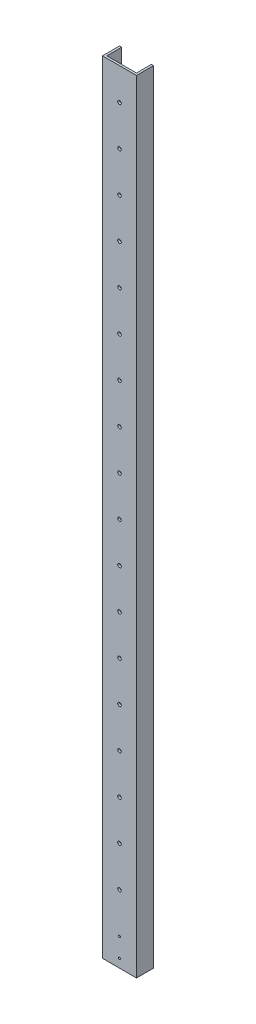
from build123d import *

# Parameters (mm, degrees)
BOSS_EXTRUDE1_DEPTH = 1168.4
CUT_EXTRUDE1_REACH  = 27.4
SKETCH2_R           = 2.667
CUT_EXTRUDE2_REACH  = 27.4
SKETCH4_R           = 1.5875


with BuildPart() as part:
    # Sketch1 → Boss-Extrude1 (new body)
    with BuildSketch(Plane(origin=(0, 0, 0), x_dir=(1, 0, 0), z_dir=(0, 1, 0))):
        Polygon((3.175, 3.175), (3.175, 25.4), (0, 25.4), (0, 0), (50.8, 0), (50.8, 25.4), (47.625, 25.4), (47.625, 3.175), align=None)
    extrude(amount=BOSS_EXTRUDE1_DEPTH)

    # Sketch2 → Cut-Extrude1 (cut, up to next)
    with BuildSketch(Plane.XY, mode=Mode.PRIVATE) as cut_extrude1_sk1:
        with Locations((25.4, 101.6)):
            Circle(SKETCH2_R)
    cut_extrude1_tool1 = extrude(cut_extrude1_sk1.sketch, amount=-CUT_EXTRUDE1_REACH, mode=Mode.PRIVATE) & part.part
    add(cut_extrude1_tool1.solids().sort_by_distance((25.4, 101.6, 0))[0], mode=Mode.SUBTRACT)
    # Sketch2 → Cut-Extrude1 (cut, up to next)
    with BuildSketch(Plane.XY, mode=Mode.PRIVATE) as cut_extrude1_sk2:
        with Locations((25.4, 161.544)):
            Circle(SKETCH2_R)
    cut_extrude1_tool2 = extrude(cut_extrude1_sk2.sketch, amount=-CUT_EXTRUDE1_REACH, mode=Mode.PRIVATE) & part.part
    add(cut_extrude1_tool2.solids().sort_by_distance((25.4, 161.544, 0))[0], mode=Mode.SUBTRACT)
    # Sketch2 → Cut-Extrude1 (cut, up to next)
    with BuildSketch(Plane.XY, mode=Mode.PRIVATE) as cut_extrude1_sk3:
        with Locations((25.4, 221.488)):
            Circle(SKETCH2_R)
    cut_extrude1_tool3 = extrude(cut_extrude1_sk3.sketch, amount=-CUT_EXTRUDE1_REACH, mode=Mode.PRIVATE) & part.part
    add(cut_extrude1_tool3.solids().sort_by_distance((25.4, 221.488, 0))[0], mode=Mode.SUBTRACT)
    # Sketch2 → Cut-Extrude1 (cut, up to next)
    with BuildSketch(Plane.XY, mode=Mode.PRIVATE) as cut_extrude1_sk4:
        with Locations((25.4, 281.432)):
            Circle(SKETCH2_R)
    cut_extrude1_tool4 = extrude(cut_extrude1_sk4.sketch, amount=-CUT_EXTRUDE1_REACH, mode=Mode.PRIVATE) & part.part
    add(cut_extrude1_tool4.solids().sort_by_distance((25.4, 281.432, 0))[0], mode=Mode.SUBTRACT)
    # Sketch2 → Cut-Extrude1 (cut, up to next)
    with BuildSketch(Plane.XY, mode=Mode.PRIVATE) as cut_extrude1_sk5:
        with Locations((25.4, 341.376)):
            Circle(SKETCH2_R)
    cut_extrude1_tool5 = extrude(cut_extrude1_sk5.sketch, amount=-CUT_EXTRUDE1_REACH, mode=Mode.PRIVATE) & part.part
    add(cut_extrude1_tool5.solids().sort_by_distance((25.4, 341.376, 0))[0], mode=Mode.SUBTRACT)
    # Sketch2 → Cut-Extrude1 (cut, up to next)
    with BuildSketch(Plane.XY, mode=Mode.PRIVATE) as cut_extrude1_sk6:
        with Locations((25.4, 401.32)):
            Circle(SKETCH2_R)
    cut_extrude1_tool6 = extrude(cut_extrude1_sk6.sketch, amount=-CUT_EXTRUDE1_REACH, mode=Mode.PRIVATE) & part.part
    add(cut_extrude1_tool6.solids().sort_by_distance((25.4, 401.32, 0))[0], mode=Mode.SUBTRACT)
    # Sketch2 → Cut-Extrude1 (cut, up to next)
    with BuildSketch(Plane.XY, mode=Mode.PRIVATE) as cut_extrude1_sk7:
        with Locations((25.4, 461.264)):
            Circle(SKETCH2_R)
    cut_extrude1_tool7 = extrude(cut_extrude1_sk7.sketch, amount=-CUT_EXTRUDE1_REACH, mode=Mode.PRIVATE) & part.part
    add(cut_extrude1_tool7.solids().sort_by_distance((25.4, 461.264, 0))[0], mode=Mode.SUBTRACT)
    # Sketch2 → Cut-Extrude1 (cut, up to next)
    with BuildSketch(Plane.XY, mode=Mode.PRIVATE) as cut_extrude1_sk8:
        with Locations((25.4, 521.208)):
            Circle(SKETCH2_R)
    cut_extrude1_tool8 = extrude(cut_extrude1_sk8.sketch, amount=-CUT_EXTRUDE1_REACH, mode=Mode.PRIVATE) & part.part
    add(cut_extrude1_tool8.solids().sort_by_distance((25.4, 521.208, 0))[0], mode=Mode.SUBTRACT)
    # Sketch2 → Cut-Extrude1 (cut, up to next)
    with BuildSketch(Plane.XY, mode=Mode.PRIVATE) as cut_extrude1_sk9:
        with Locations((25.4, 581.152)):
            Circle(SKETCH2_R)
    cut_extrude1_tool9 = extrude(cut_extrude1_sk9.sketch, amount=-CUT_EXTRUDE1_REACH, mode=Mode.PRIVATE) & part.part
    add(cut_extrude1_tool9.solids().sort_by_distance((25.4, 581.152, 0))[0], mode=Mode.SUBTRACT)
    # Sketch2 → Cut-Extrude1 (cut, up to next)
    with BuildSketch(Plane.XY, mode=Mode.PRIVATE) as cut_extrude1_sk10:
        with Locations((25.4, 641.096)):
            Circle(SKETCH2_R)
    cut_extrude1_tool10 = extrude(cut_extrude1_sk10.sketch, amount=-CUT_EXTRUDE1_REACH, mode=Mode.PRIVATE) & part.part
    add(cut_extrude1_tool10.solids().sort_by_distance((25.4, 641.096, 0))[0], mode=Mode.SUBTRACT)
    # Sketch2 → Cut-Extrude1 (cut, up to next)
    with BuildSketch(Plane.XY, mode=Mode.PRIVATE) as cut_extrude1_sk11:
        with Locations((25.4, 701.04)):
            Circle(SKETCH2_R)
    cut_extrude1_tool11 = extrude(cut_extrude1_sk11.sketch, amount=-CUT_EXTRUDE1_REACH, mode=Mode.PRIVATE) & part.part
    add(cut_extrude1_tool11.solids().sort_by_distance((25.4, 701.04, 0))[0], mode=Mode.SUBTRACT)
    # Sketch2 → Cut-Extrude1 (cut, up to next)
    with BuildSketch(Plane.XY, mode=Mode.PRIVATE) as cut_extrude1_sk12:
        with Locations((25.4, 760.984)):
            Circle(SKETCH2_R)
    cut_extrude1_tool12 = extrude(cut_extrude1_sk12.sketch, amount=-CUT_EXTRUDE1_REACH, mode=Mode.PRIVATE) & part.part
    add(cut_extrude1_tool12.solids().sort_by_distance((25.4, 760.984, 0))[0], mode=Mode.SUBTRACT)
    # Sketch2 → Cut-Extrude1 (cut, up to next)
    with BuildSketch(Plane.XY, mode=Mode.PRIVATE) as cut_extrude1_sk13:
        with Locations((25.4, 820.928)):
            Circle(SKETCH2_R)
    cut_extrude1_tool13 = extrude(cut_extrude1_sk13.sketch, amount=-CUT_EXTRUDE1_REACH, mode=Mode.PRIVATE) & part.part
    add(cut_extrude1_tool13.solids().sort_by_distance((25.4, 820.928, 0))[0], mode=Mode.SUBTRACT)
    # Sketch2 → Cut-Extrude1 (cut, up to next)
    with BuildSketch(Plane.XY, mode=Mode.PRIVATE) as cut_extrude1_sk14:
        with Locations((25.4, 880.872)):
            Circle(SKETCH2_R)
    cut_extrude1_tool14 = extrude(cut_extrude1_sk14.sketch, amount=-CUT_EXTRUDE1_REACH, mode=Mode.PRIVATE) & part.part
    add(cut_extrude1_tool14.solids().sort_by_distance((25.4, 880.872, 0))[0], mode=Mode.SUBTRACT)
    # Sketch2 → Cut-Extrude1 (cut, up to next)
    with BuildSketch(Plane.XY, mode=Mode.PRIVATE) as cut_extrude1_sk15:
        with Locations((25.4, 940.816)):
            Circle(SKETCH2_R)
    cut_extrude1_tool15 = extrude(cut_extrude1_sk15.sketch, amount=-CUT_EXTRUDE1_REACH, mode=Mode.PRIVATE) & part.part
    add(cut_extrude1_tool15.solids().sort_by_distance((25.4, 940.816, 0))[0], mode=Mode.SUBTRACT)
    # Sketch2 → Cut-Extrude1 (cut, up to next)
    with BuildSketch(Plane.XY, mode=Mode.PRIVATE) as cut_extrude1_sk16:
        with Locations((25.4, 1000.76)):
            Circle(SKETCH2_R)
    cut_extrude1_tool16 = extrude(cut_extrude1_sk16.sketch, amount=-CUT_EXTRUDE1_REACH, mode=Mode.PRIVATE) & part.part
    add(cut_extrude1_tool16.solids().sort_by_distance((25.4, 1000.76, 0))[0], mode=Mode.SUBTRACT)
    # Sketch2 → Cut-Extrude1 (cut, up to next)
    with BuildSketch(Plane.XY, mode=Mode.PRIVATE) as cut_extrude1_sk17:
        with Locations((25.4, 1060.704)):
            Circle(SKETCH2_R)
    cut_extrude1_tool17 = extrude(cut_extrude1_sk17.sketch, amount=-CUT_EXTRUDE1_REACH, mode=Mode.PRIVATE) & part.part
    add(cut_extrude1_tool17.solids().sort_by_distance((25.4, 1060.704, 0))[0], mode=Mode.SUBTRACT)
    # Sketch2 → Cut-Extrude1 (cut, up to next)
    with BuildSketch(Plane.XY, mode=Mode.PRIVATE) as cut_extrude1_sk18:
        with Locations((25.4, 1120.648)):
            Circle(SKETCH2_R)
    cut_extrude1_tool18 = extrude(cut_extrude1_sk18.sketch, amount=-CUT_EXTRUDE1_REACH, mode=Mode.PRIVATE) & part.part
    add(cut_extrude1_tool18.solids().sort_by_distance((25.4, 1120.648, 0))[0], mode=Mode.SUBTRACT)

    # Sketch4 → Cut-Extrude2 (cut, up to next)
    with BuildSketch(Plane.XY, mode=Mode.PRIVATE) as cut_extrude2_sk1:
        with Locations((25.4, 41.275)):
            Circle(SKETCH4_R)
    cut_extrude2_tool1 = extrude(cut_extrude2_sk1.sketch, amount=-CUT_EXTRUDE2_REACH, mode=Mode.PRIVATE) & part.part
    add(cut_extrude2_tool1.solids().sort_by_distance((25.4, 41.275, 0))[0], mode=Mode.SUBTRACT)
    # Sketch4 → Cut-Extrude2 (cut, up to next)
    with BuildSketch(Plane.XY, mode=Mode.PRIVATE) as cut_extrude2_sk2:
        with Locations((25.4, 12.7)):
            Circle(SKETCH4_R)
    cut_extrude2_tool2 = extrude(cut_extrude2_sk2.sketch, amount=-CUT_EXTRUDE2_REACH, mode=Mode.PRIVATE) & part.part
    add(cut_extrude2_tool2.solids().sort_by_distance((25.4, 12.7, 0))[0], mode=Mode.SUBTRACT)


solid = part.part
